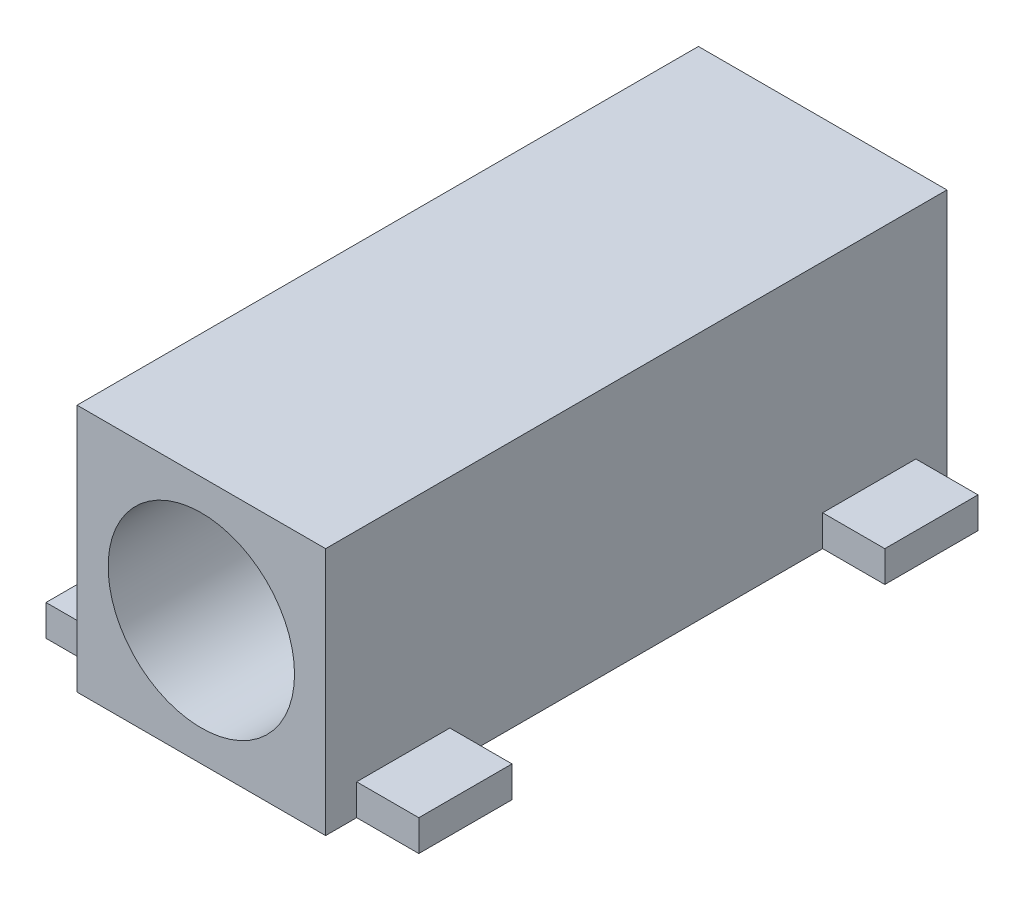
from build123d import *

# Parameters (mm, degrees)
SKETCH1_W           = 4
SKETCH1_H           = 4
SKETCH1_R           = 1.5
BOSS_EXTRUDE1_DEPTH = 10
SKETCH3_W           = 1.5
SKETCH3_H           = 0.5
BOSS_EXTRUDE2_DEPTH = 1
SKETCH4_W           = 1.5
SKETCH4_H           = 0.5
BOSS_EXTRUDE3_DEPTH = 1


with BuildPart() as part:
    # Sketch1 → Boss-Extrude1 (new body)
    with BuildSketch(Plane.XY):
        Rectangle(SKETCH1_W, SKETCH1_H)
        Circle(SKETCH1_R, mode=Mode.SUBTRACT)
    extrude(amount=BOSS_EXTRUDE1_DEPTH)

    # Sketch3 → Boss-Extrude2 (add)
    with BuildSketch(Plane(origin=(2, 0, 0), x_dir=(0, 0, -1), z_dir=(1, 0, 0))):
        with Locations((-8.75, -1.75)):
            Rectangle(SKETCH3_W, SKETCH3_H)
        with Locations((-1.25, -1.75)):
            Rectangle(SKETCH3_W, SKETCH3_H)
    extrude(amount=BOSS_EXTRUDE2_DEPTH)

    # Sketch4 → Boss-Extrude3 (add)
    with BuildSketch(Plane.ZY.offset(2)):
        with Locations((8.75, -1.75)):
            Rectangle(SKETCH4_W, SKETCH4_H)
    extrude(amount=BOSS_EXTRUDE3_DEPTH)


solid = part.part
